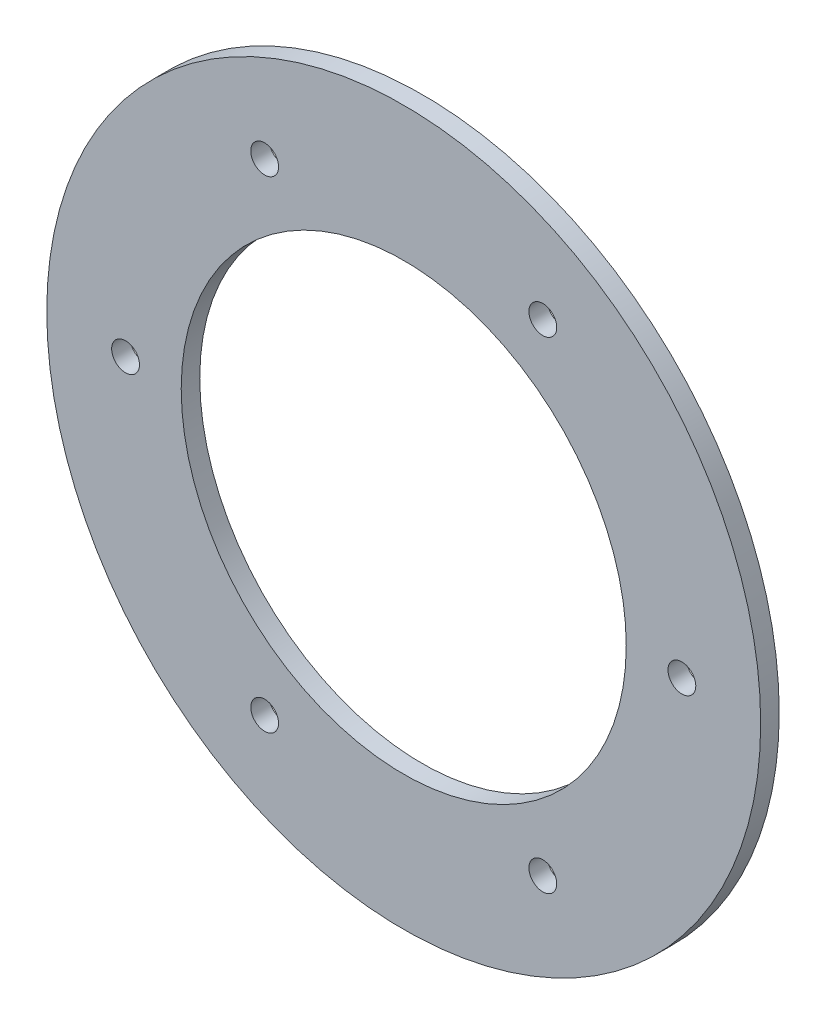
from build123d import *

# Parameters (mm, degrees)
MODEL_R             = 38.5
MODEL_R_2           = 1.5
MODEL_R_3           = 24
BOSS_EXTRUDE1_DEPTH = 2


with BuildPart() as part:
    # Model → Boss-Extrude1 (new body)
    with BuildSketch(Plane.XY):
        Circle(MODEL_R)
        with Locations((-30, 0)):
            Circle(MODEL_R_2, mode=Mode.SUBTRACT)
        with Locations((-15, -25.980762114)):
            Circle(MODEL_R_2, mode=Mode.SUBTRACT)
        with Locations((15, 25.980762114)):
            Circle(MODEL_R_2, mode=Mode.SUBTRACT)
        with Locations((-15, 25.980762114)):
            Circle(MODEL_R_2, mode=Mode.SUBTRACT)
        with Locations((15, -25.980762114)):
            Circle(MODEL_R_2, mode=Mode.SUBTRACT)
        with Locations((30, 0)):
            Circle(MODEL_R_2, mode=Mode.SUBTRACT)
        Circle(MODEL_R_3, mode=Mode.SUBTRACT)
    extrude(amount=BOSS_EXTRUDE1_DEPTH)


solid = part.part
